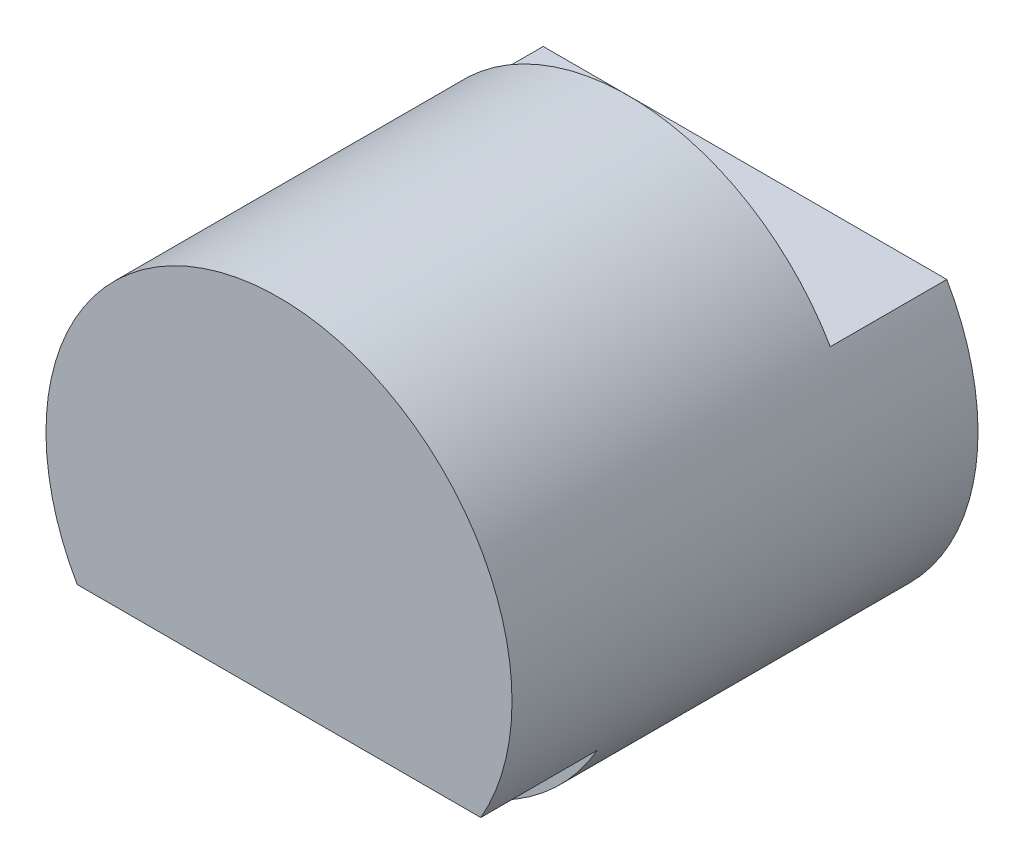
from build123d import *

# Parameters (mm, degrees)
SKETCH1_R           = 2
BOSS_EXTRUDE1_DEPTH = 3
BOSS_EXTRUDE2_DEPTH = 1
CUT_EXTRUDE1_DEPTH  = 1
BOSS_EXTRUDE3_DEPTH = 1


with BuildPart() as part:
    # Sketch1 → Boss-Extrude1 (new body)
    with BuildSketch(Plane.XY):
        Circle(SKETCH1_R)
    extrude(amount=BOSS_EXTRUDE1_DEPTH)

    # Sketch2 → Boss-Extrude2 (add)
    with BuildSketch(Plane.XY.offset(3)):
        with BuildLine():
            Line((-1.732050808, 1), (1.732050808, 1))
            ThreePointArc((1.732050808, 1), (0, 2), (-1.732050808, 1))
        make_face()
    extrude(amount=BOSS_EXTRUDE2_DEPTH)

    # Sketch3 → Cut-Extrude1 (cut)
    with BuildSketch(Plane(origin=(0, 0, 0), x_dir=(-1, 0, 0), z_dir=(0, 0, -1))):
        with BuildLine():
            Line((1.732050808, 1), (-1.732050808, 1))
            ThreePointArc((-1.732050808, 1), (0, 2), (1.732050808, 1))
        make_face()
    extrude(amount=-CUT_EXTRUDE1_DEPTH, mode=Mode.SUBTRACT)

    # Sketch4 → Boss-Extrude3 (add)
    with BuildSketch(Plane.XY.offset(3)):
        with BuildLine():
            Line((-1.732050808, -1), (1.732050808, -1))
            ThreePointArc((1.732050808, -1), (2, 0), (1.732050808, 1))
            Line((1.732050808, 1), (-1.732050808, 1))
            ThreePointArc((-1.732050808, 1), (-2, 0), (-1.732050808, -1))
        make_face()
    extrude(amount=BOSS_EXTRUDE3_DEPTH)


solid = part.part
